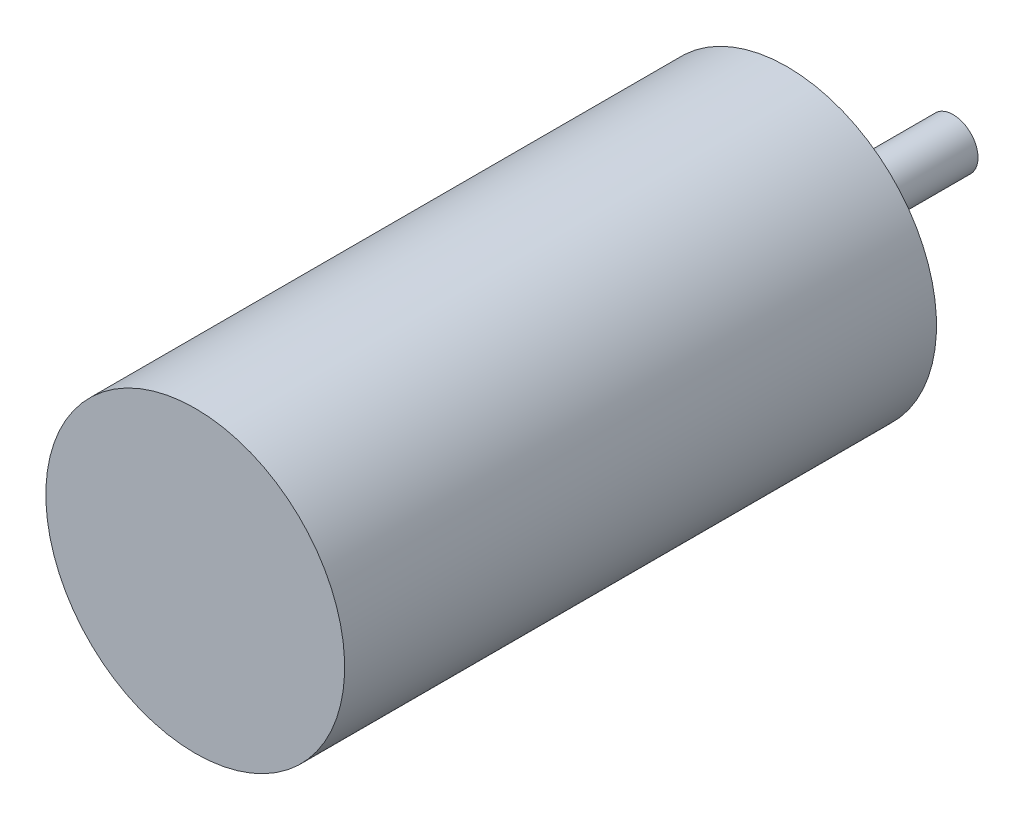
from build123d import *

# Parameters (mm, degrees)
SKETCH2_R          = 1.25
CUT_EXTRUDE1_DEPTH = 6.5


with BuildPart() as part:
    # Sketch1 → Revolve1 (revolve)
    with BuildSketch(Plane(origin=(0, 0, 0), x_dir=(0, 0, -1), z_dir=(1, 0, 0))):
        Polygon((0, 0), (0, 18), (71.3, 18), (71.3, 6.5), (72.5, 6.5), (72.5, 4.863636364), (74.65, 4.863636364), (74.65, 3), (91.3, 3), (91.3, 0), align=None)
    revolve(axis=Axis((0, 0, -91.3), (0, 0, 1)))

    # Sketch2 → Cut-Extrude1 (cut)
    with BuildSketch(Plane(origin=(0, 0, -71.3), x_dir=(-1, 0, 0), z_dir=(0, 0, -1))):
        with Locations((0, 9.5)):
            Circle(SKETCH2_R)
        with Locations((8.227241336, 4.75)):
            Circle(SKETCH2_R)
        with Locations((8.227241336, -4.75)):
            Circle(SKETCH2_R)
        with Locations((0, -9.5)):
            Circle(SKETCH2_R)
        with Locations((-8.227241336, -4.75)):
            Circle(SKETCH2_R)
        with Locations((-8.227241336, 4.75)):
            Circle(SKETCH2_R)
    extrude(amount=-CUT_EXTRUDE1_DEPTH, mode=Mode.SUBTRACT)


solid = part.part
